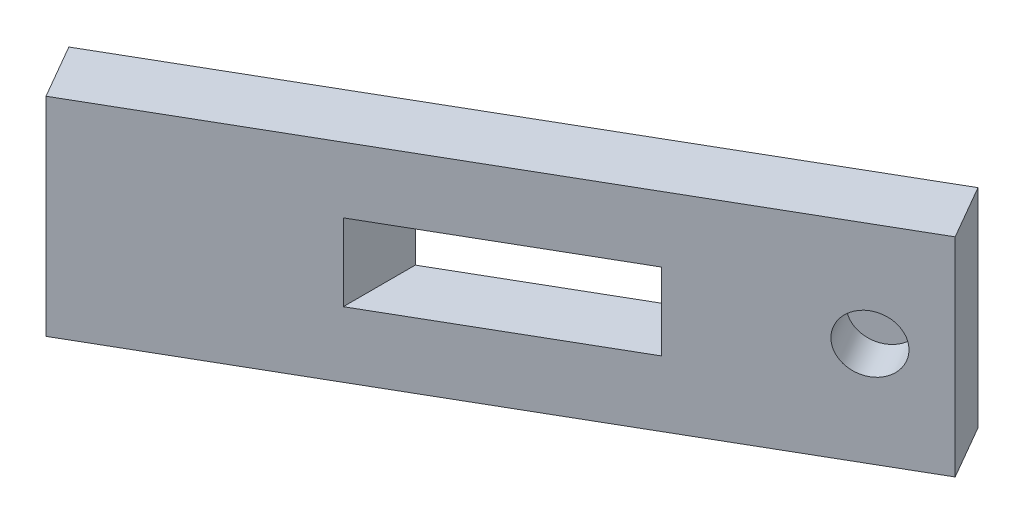
from build123d import *

# Parameters (mm, degrees)
EXTRUDE_1_DEPTH      = 5
EXTRUDE_1_DEPTH_BACK = 5
CUT_EXTRUDE_1_DEPTH  = 1.85
SKETCH_3_R           = 1.375
CUT_EXTRUDE_2_DEPTH  = 2


with BuildPart() as part:
    # 草圖1 → 填料-伸長1 (new, two sides: drawn at the far end of the back side and taken through both)
    with BuildSketch(Plane(origin=(0, 0, 0), x_dir=(1, 0, 0), z_dir=(0, 1, 0)).offset(-EXTRUDE_1_DEPTH_BACK)):
        Polygon((-24.417534462, -5.938079912), (-25.917534462, -3.340003701), (1.795278459, 12.659996299), (3.295278459, 10.061920088), align=None)
    extrude(amount=EXTRUDE_1_DEPTH + EXTRUDE_1_DEPTH_BACK)

    # 草圖2 → 除料-伸長1 (cut, symmetric)
    with BuildSketch(Plane(origin=(0, 0, 0), x_dir=(1, 0, 0), z_dir=(0, 1, 0))):
        Polygon((-15.35631853, 2.4), (-15.35631853, -0.706584455), (-5.65631853, 4.893713156), (-5.65631853, 8.357814772), (-15.35631853, 2.75751716), align=None)
    extrude(amount=CUT_EXTRUDE_1_DEPTH, both=True, mode=Mode.SUBTRACT)

    # 草圖3 → 除料-伸長2 (cut)
    with BuildSketch(Plane(origin=(-3.533119589, 0, -6.119542637), x_dir=(0.8660254037844386, 0, -0.5000000000000003), z_dir=(0.5000000000000003, 0, 0.8660254037844386))):
        with Locations((4.884754902, 0)):
            Circle(SKETCH_3_R)
    extrude(amount=-CUT_EXTRUDE_2_DEPTH, mode=Mode.SUBTRACT)


solid = part.part
